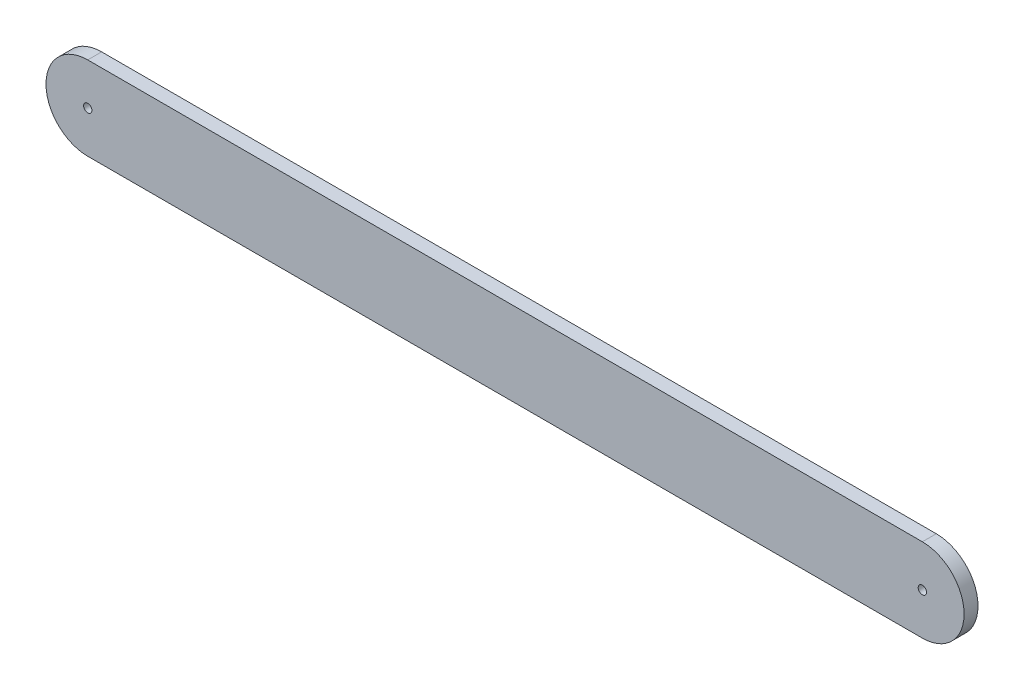
from build123d import *

# Parameters (mm, degrees)
SKETCH1_R           = 1.5
BOSS_EXTRUDE1_DEPTH = 5


with BuildPart() as part:
    # Sketch1 → Boss-Extrude1 (new body)
    with BuildSketch(Plane.XY):
        with BuildLine():
            Line((-133.993902439, 15), (166.006097561, 15))
            ThreePointArc((166.006097561, 15), (181.006097561, 0), (166.006097561, -15))
            Line((166.006097561, -15), (-133.993902439, -15))
            ThreePointArc((-133.993902439, -15), (-148.993902439, 0), (-133.993902439, 15))
        make_face()
        with Locations((-133.993902439, 0)):
            Circle(SKETCH1_R, mode=Mode.SUBTRACT)
        with Locations((166.006097561, 0)):
            Circle(SKETCH1_R, mode=Mode.SUBTRACT)
    extrude(amount=BOSS_EXTRUDE1_DEPTH)


solid = part.part
